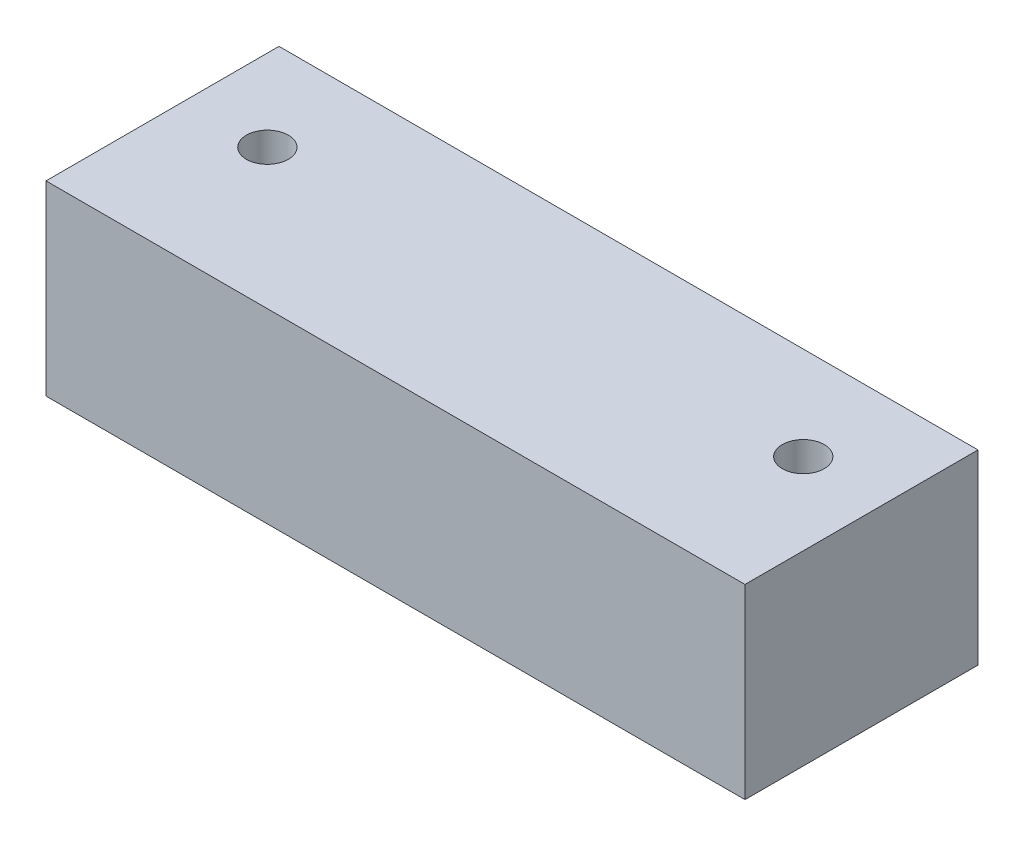
from build123d import *

# Parameters (mm, degrees)
SKETCH1_W               = 300
SKETCH1_H               = 80
BOSS_EXTRUDE1_DEPTH     = 50
SKETCH2_R               = 9
CUT_EXTRUDE1_DEPTH      = 41
CUT_EXTRUDE1_DEPTH_BACK = 41


with BuildPart() as part:
    # Sketch1 → Boss-Extrude1 (new body, symmetric)
    with BuildSketch(Plane.XY):
        Rectangle(SKETCH1_W, SKETCH1_H)
    extrude(amount=BOSS_EXTRUDE1_DEPTH, both=True)

    # Sketch2 → Cut-Extrude1 (cut, two sides)
    with BuildSketch(Plane(origin=(0, 0, 0), x_dir=(1, 0, 0), z_dir=(0, 1, 0))) as cut_extrude1_sk:
        with Locations((-115, 10)):
            Circle(SKETCH2_R)
        with Locations((115, 10)):
            Circle(SKETCH2_R)
    extrude(amount=CUT_EXTRUDE1_DEPTH, mode=Mode.SUBTRACT)
    extrude(cut_extrude1_sk.sketch, amount=-CUT_EXTRUDE1_DEPTH_BACK, mode=Mode.SUBTRACT)


solid = part.part
